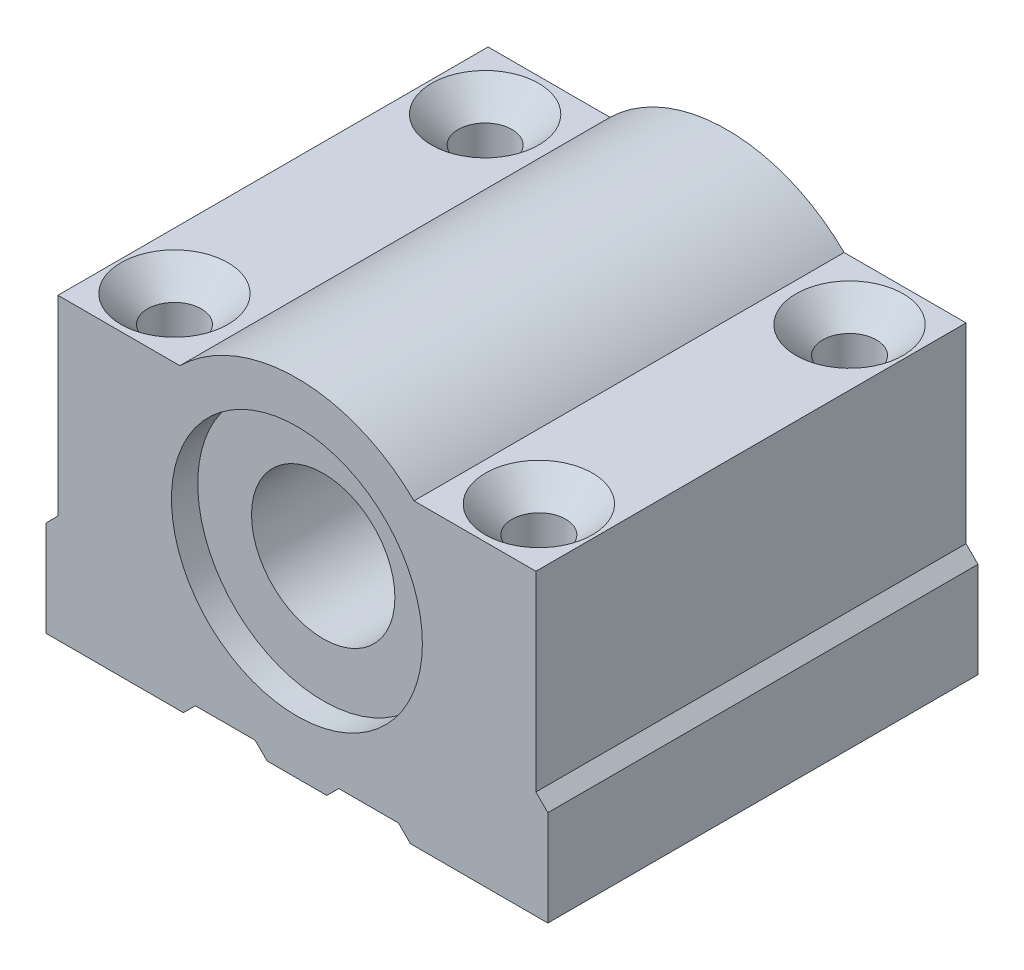
from build123d import *

# Parameters (mm, degrees)
ESBO_O1_R                                            = 6
EXTRUS_O1_DEPTH                                      = 36
ESBO_O2_R                                            = 10.5
EXTRUS_O2_DEPTH                                      = 2.2
ESBO_O3_R                                            = 10.5
EXTRUS_O3_DEPTH                                      = 2.2
ESBO_O4_R                                            = 1.65
EXTRUS_O4_DEPTH                                      = 26
ESCAREADO_PARA_PARAFUSO_DE_M_QUINA_COM_C_D           = 5.5
ESCAREADO_PARA_PARAFUSO_DE_M_QUINA_COM_C_DEPTH       = 12
ESCAREADO_PARA_PARAFUSO_DE_M_QUINA_COM_C_CSINK_D     = 9
ESCAREADO_PARA_PARAFUSO_DE_M_QUINA_COM_C_CSINK_ANGLE = 90
ESCAREADO_PARA_PARAFUSO_DE_M_QUINA_COM_C_TIP         = 1.652366702
ESCAREADO_PARA_SFHCS_M41_D                           = 4.5
ESCAREADO_PARA_SFHCS_M41_CSINK_D                     = 8.96
ESCAREADO_PARA_SFHCS_M41_CSINK_ANGLE                 = 90


with BuildPart() as part:
    # Esboço1 → Extrusão1 (new body)
    with BuildSketch(Plane.XY):
        with BuildLine():
            Line((-20, 10), (-20, -6))
            Line((-20, -6), (-21, -7))
            Line((-21, -7), (-21, -15))
            Line((-21, -15), (-9.5, -15))
            Line((-9.5, -15), (-8.5, -14))
            Line((-8.5, -14), (-3.5, -14))
            Line((-3.5, -14), (-2.5, -15))
            Line((-2.5, -15), (2.5, -15))
            Line((2.5, -15), (3.5, -14))
            Line((3.5, -14), (8.5, -14))
            Line((8.5, -14), (9.5, -15))
            Line((9.5, -15), (21, -15))
            Line((21, -15), (21, -7))
            Line((21, -7), (20, -6))
            Line((20, -6), (20, 10))
            Line((20, 10), (9.797958971, 10))
            ThreePointArc((9.797958971, 10), (0, 14), (-9.797958971, 10))
            Line((-9.797958971, 10), (-20, 10))
        make_face()
        Circle(ESBO_O1_R, mode=Mode.SUBTRACT)
    extrude(amount=EXTRUS_O1_DEPTH)

    # Esboço2 → Extrusão2 (cut)
    with BuildSketch(Plane.XY.offset(36)):
        Circle(ESBO_O2_R)
    extrude(amount=-EXTRUS_O2_DEPTH, mode=Mode.SUBTRACT)

    # Esboço3 → Extrusão3 (cut)
    with BuildSketch(Plane(origin=(0, 0, 0), x_dir=(-1, 0, 0), z_dir=(0, 0, -1))):
        Circle(ESBO_O3_R)
    extrude(amount=-EXTRUS_O3_DEPTH, mode=Mode.SUBTRACT)

    # Esboço4 → Extrusão4 (cut, through all)
    with BuildSketch(Plane(origin=(0, 10, 0), x_dir=(1, 0, 0), z_dir=(0, 1, 0))):
        with Locations((15.25, -5)):
            Circle(ESBO_O4_R)
        with Locations((15.25, -31)):
            Circle(ESBO_O4_R)
        with Locations((-15.25, -5)):
            Circle(ESBO_O4_R)
        with Locations((-15.25, -31)):
            Circle(ESBO_O4_R)
    extrude(amount=-EXTRUS_O4_DEPTH, mode=Mode.SUBTRACT)

    # Escareado para parafuso de máquina com cabeça chata de M52
    with Locations(Plane(origin=(-15.25, -15, 31), x_dir=(0, 0, -1), z_dir=(0, -1, 0))):
        with Locations((0, 0), (26, 0), (26, 30.5), (0, 30.5)):
            CounterSinkHole(ESCAREADO_PARA_PARAFUSO_DE_M_QUINA_COM_C_D / 2, ESCAREADO_PARA_PARAFUSO_DE_M_QUINA_COM_C_CSINK_D / 2, depth=ESCAREADO_PARA_PARAFUSO_DE_M_QUINA_COM_C_DEPTH, counter_sink_angle=ESCAREADO_PARA_PARAFUSO_DE_M_QUINA_COM_C_CSINK_ANGLE)
            with Locations((0, 0, -(ESCAREADO_PARA_PARAFUSO_DE_M_QUINA_COM_C_DEPTH + ESCAREADO_PARA_PARAFUSO_DE_M_QUINA_COM_C_TIP / 2))):  # 118° drill point
                Cone(0, ESCAREADO_PARA_PARAFUSO_DE_M_QUINA_COM_C_D / 2, ESCAREADO_PARA_PARAFUSO_DE_M_QUINA_COM_C_TIP, mode=Mode.SUBTRACT)

    # Escareado para SFHCS M41 (through all)
    with Locations(Plane(origin=(-15.25, 10, 5), x_dir=(0, 0, 1), z_dir=(0, 1, 0))):
        with Locations((0, 0), (26, 0), (26, 30.5), (0, 30.5)):
            CounterSinkHole(ESCAREADO_PARA_SFHCS_M41_D / 2, ESCAREADO_PARA_SFHCS_M41_CSINK_D / 2, counter_sink_angle=ESCAREADO_PARA_SFHCS_M41_CSINK_ANGLE)


solid = part.part
